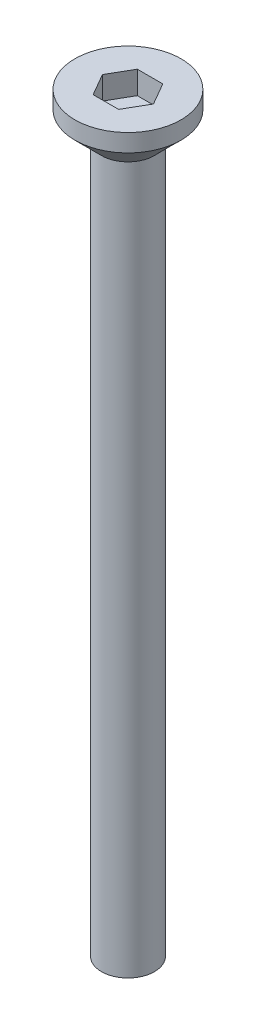
from build123d import *

# Parameters (mm, degrees)
SKETCH_1_R            = 3
EXTRUDE_251_DEPTH     = 2.5
CHAMFER_1_SIZE        = 1.5
CUT_EXTRUDE_459_DEPTH = 1.3
SKETCH_3_R            = 1.5
EXTRUDE_571_DEPTH     = 40


with BuildPart() as part:
    # 草图1 → Extrude 251 (new body)
    with BuildSketch(Plane(origin=(0, 0, 0), x_dir=(1, 0, 0), z_dir=(0, 1, 0))):
        Circle(SKETCH_1_R)
    extrude(amount=EXTRUDE_251_DEPTH)

    # 倒角1
    chamfer_1_edges = [part.edges().sort_by_distance(p)[0] for p in [
        (-3, 0, 0),
    ]]
    chamfer(chamfer_1_edges, length=CHAMFER_1_SIZE)

    # 草图2 → Cut-Extrude 459 (cut)
    with BuildSketch(Plane(origin=(0, 2.5, 0), x_dir=(1, 0, 0), z_dir=(0, 1, 0))):
        Polygon((1.443375673, 0), (0.721687836, 1.25), (-0.721687836, 1.25), (-1.443375673, 0), (-0.721687836, -1.25), (0.721687836, -1.25), align=None)
    extrude(amount=-CUT_EXTRUDE_459_DEPTH, mode=Mode.SUBTRACT)

    # 草图3 → Extrude 571 (add)
    with BuildSketch(Plane.XZ):
        Circle(SKETCH_3_R)
    extrude(amount=EXTRUDE_571_DEPTH)


solid = part.part
